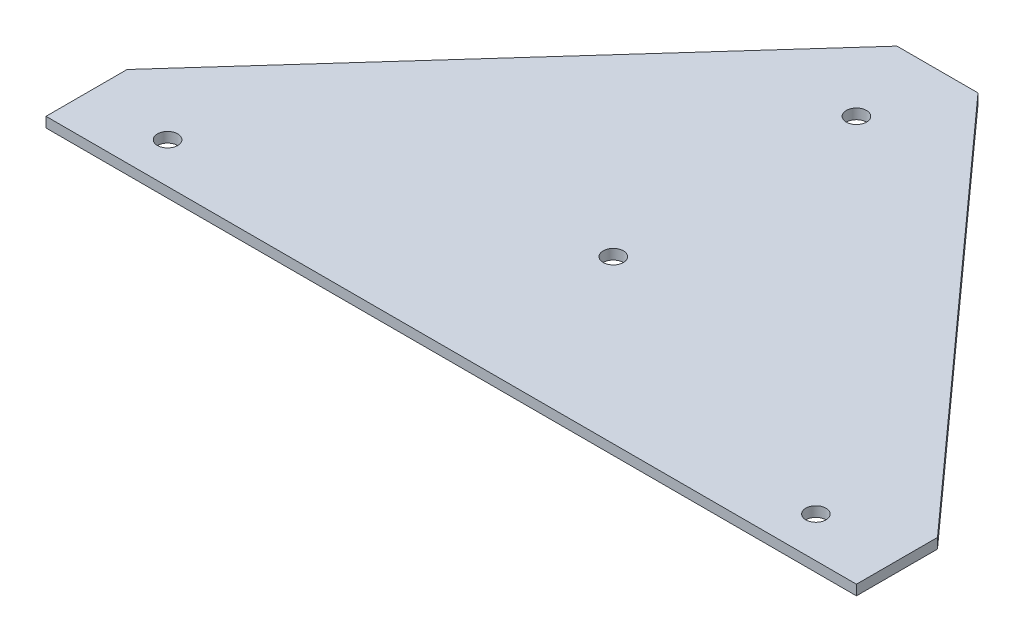
from build123d import *

# Parameters (mm, degrees)
SKETCH1_R           = 3.175
BOSS_EXTRUDE1_DEPTH = 3.175


with BuildPart() as part:
    # Sketch1 → Boss-Extrude1 (new body)
    with BuildSketch(Plane(origin=(0, 0, 0), x_dir=(1, 0, 0), z_dir=(0, 1, 0))):
        Polygon((127, 0), (-127, 0), (-127, 25.4), (-12.7, 152.4), (12.7, 152.4), (127, 25.4), align=None)
        with Locations((0, 127)):
            Circle(SKETCH1_R, mode=Mode.SUBTRACT)
        with Locations((0, 50.8)):
            Circle(SKETCH1_R, mode=Mode.SUBTRACT)
        with Locations((-101.6, 12.7)):
            Circle(SKETCH1_R, mode=Mode.SUBTRACT)
        with Locations((101.6, 12.7)):
            Circle(SKETCH1_R, mode=Mode.SUBTRACT)
    extrude(amount=BOSS_EXTRUDE1_DEPTH)


solid = part.part
